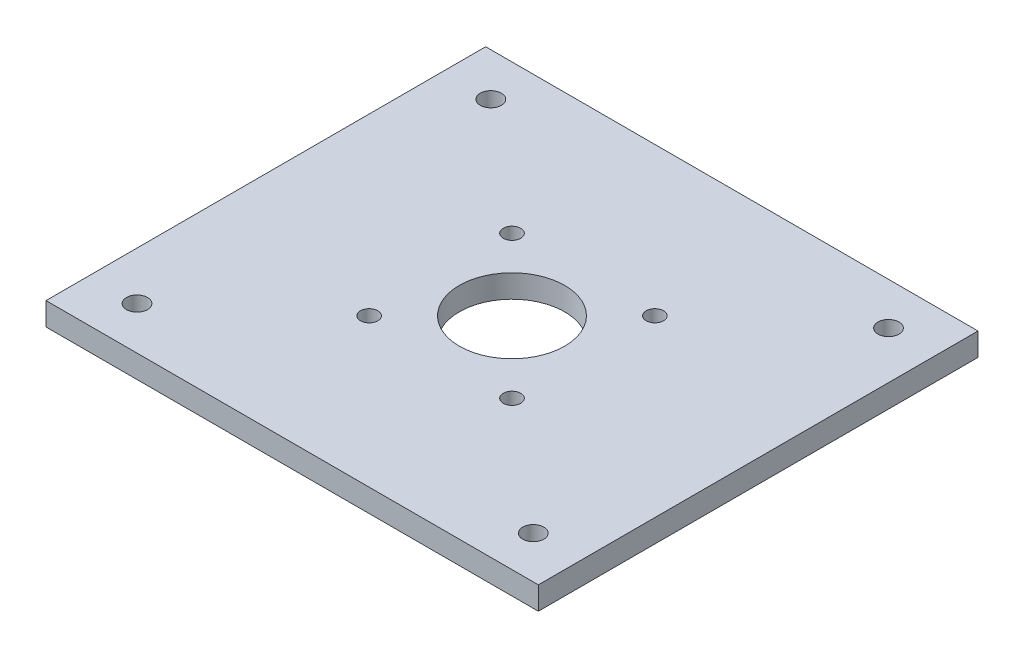
from build123d import *

# Parameters (mm, degrees)
SKETCH1_W           = 107.5
SKETCH1_H           = 96
BOSS_EXTRUDE1_DEPTH = 5
SKETCH2_R           = 1.9
SKETCH2_R_2         = 11.5
SKETCH2_R_3         = 2.3
CUT_EXTRUDE3_DEPTH  = 5


with BuildPart() as part:
    # Sketch1 → Boss-Extrude1 (new body)
    with BuildSketch(Plane(origin=(0, 0, 0), x_dir=(1, 0, 0), z_dir=(0, 1, 0))):
        Rectangle(SKETCH1_W, SKETCH1_H)
    extrude(amount=BOSS_EXTRUDE1_DEPTH)

    # Sketch2 → Cut-Extrude3 (cut)
    with BuildSketch(Plane(origin=(0, 0, 0), x_dir=(1, 0, 0), z_dir=(0, 1, 0))):
        with Locations((-15.6, 15.6)):
            Circle(SKETCH2_R)
        with Locations((15.6, 15.6)):
            Circle(SKETCH2_R)
        with Locations((15.6, -15.6)):
            Circle(SKETCH2_R)
        with Locations((-15.6, -15.6)):
            Circle(SKETCH2_R)
        Circle(SKETCH2_R_2)
        with Locations((-43.255523212, -38.628188171)):
            Circle(SKETCH2_R_3)
        with Locations((43.42574654, 38.780201561)):
            Circle(SKETCH2_R_3)
        with Locations((-43.255523212, 38.628188171)):
            Circle(SKETCH2_R_3)
        with Locations((43.42574654, -38.780201561)):
            Circle(SKETCH2_R_3)
    extrude(amount=CUT_EXTRUDE3_DEPTH, mode=Mode.SUBTRACT)


solid = part.part
